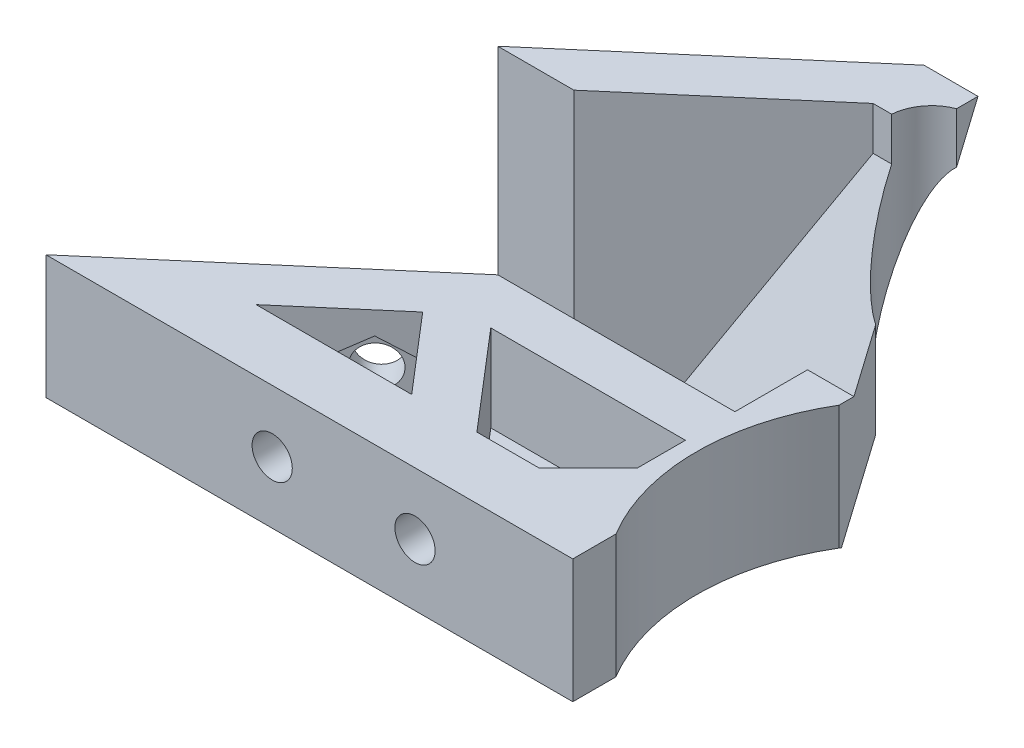
from build123d import *

# Parameters (mm, degrees)
CROQUIS1_R                              = 15.25
CROQUIS1_R_2                            = 2.125
SOPORTE_CAJA_REDUCTORA_DEPTH            = 20
CROQUIS3_R                              = 2.125
CORTAR_EXTRUIR1_DEPTH                   = 51.423828692
REDONDEO1_R                             = 5
BOSS_EXTRUDE1_DEPTH                     = 20
CUT_EXTRUDE1_REACH                      = 55.852
SKETCH2_R                               = 1.625
CUT_EXTRUDE2_DEPTH                      = 2
SKETCH4_R                               = 1.625
CUT_EXTRUDE3_DEPTH                      = 63.291652731
CUT_EXTRUDE4_START                      = -4.5
CUT_EXTRUDE4_DEPTH                      = 2
CROQUIS6_W                              = 4.75
CROQUIS6_H                              = 4.75
CORTAR_EXTRUIR17_DEPTH                  = 42.231056256
CROQUIS7_W                              = 60
CROQUIS7_H                              = 20
CORTAR_EXTRUIR18_DEPTH                  = 51.423828692
SALIENTE_EXTRUIR2_DEPTH                 = 49
SOPORTE_START                           = -15
SOPORTE_MOTOR_DEPTH                     = 15
CROQUIS12_R                             = 2.125
AGUJEROS_DE_SUJECION_A_BASE_DEPTH       = 84.087679592
TUERCA_START                            = -4
TUERCA_AGUJERO_DE_SUJECION_A_BASE_DEPTH = 10
SALIENTE_EXTRUIR4_DEPTH                 = 15
CORTAR_EXTRUIR19_DEPTH                  = 25
CROQUIS14_W                             = 50
CROQUIS14_H                             = 118
CORTAR_EXTRUIR22_DEPTH                  = 146.556045907
CROQUIS15_W                             = 10
CROQUIS15_H                             = 7
CORTAR_EXTRUIR23_DEPTH                  = 42.231056256
CORTAR_EXTRUIR24_DEPTH                  = 42.231056256
CROQUIS18_W                             = 40
CROQUIS18_H                             = 10
CORTAR_EXTRUIR25_DEPTH                  = 44.27311521
SALIENTE_EXTRUIR5_DEPTH                 = 10
CROQUIS20_R                             = 1
CORTAR_EXTRUIR26_DEPTH                  = 49.229270158
CORTAR_EXTRUIR27_REACH                  = 62.959
CORTAR_EXTRUIR27_END_RADIUS             = 15.25
CROQUIS21_R                             = 1.625
CROQUIS22_R                             = 2.125
CROQUIS22_R_2                           = 1
SALIENTE_EXTRUIR6_DEPTH                 = 10
CROQUIS23_R                             = 1.625
CORTAR_EXTRUIR28_DEPTH                  = 52.269508521
CORTAR_EXTRUIR29_START                  = -3
CORTAR_EXTRUIR29_DEPTH                  = 10
SALIENTE_EXTRUIR7_DEPTH                 = 10
CORTAR_EXTRUIR30_REACH                  = 72.235
CROQUIS27_R                             = 1.625
CORTAR_EXTRUIR31_REACH                  = 75.235
CORTAR_EXTRUIR31_START                  = -3
CORTAR_EXTRUIR32_REACH                  = 58.612
CROQUIS29_R                             = 1.625
CORTAR_EXTRUIR33_REACH                  = 61.112
CORTAR_EXTRUIR33_START                  = -2.5
CROQUIS35_W                             = 13.305418987
CROQUIS35_H                             = 6.826864192
CORTAR_EXTRUIR34_DEPTH                  = 63.931555098
CORTAR_EXTRUIR34_DEPTH_BACK             = 63.931555098
CORTAR_EXTRUIR35_START                  = -3
CORTAR_EXTRUIR35_DEPTH                  = 10
SALIENTE_EXTRUIR8_DEPTH                 = 10
SALIENTE_EXTRUIR9_DEPTH                 = 13
SALIENTE_EXTRUIR10_DEPTH                = 3
CROQUIS40_W                             = 106.583537839
CROQUIS40_H                             = 47.391515964
CORTAR_EXTRUIR36_DEPTH                  = 80.887064817
CORTAR_EXTRUIR36_DEPTH_BACK             = 80.887064817
CROQUIS41_W                             = 24.558856908
CROQUIS41_H                             = 18.206234432
CORTAR_EXTRUIR37_DEPTH                  = 80.887064817
CORTAR_EXTRUIR37_DEPTH_BACK             = 80.887064817
CROQUIS42_W                             = 39.793611955
CROQUIS42_H                             = 36.552695193
CORTAR_EXTRUIR38_DEPTH                  = 63.931555082
CORTAR_EXTRUIR38_DEPTH_BACK             = 63.931555082
SALIENTE_EXTRUIR11_DEPTH                = 3
CROQUIS44_R                             = 17.5
CORTAR_EXTRUIR39_DEPTH                  = 63.931555082
CORTAR_EXTRUIR39_DEPTH_BACK             = 63.931555082
SALIENTE_EXTRUIR12_DEPTH                = 16
CORTAR_EXTRUIR40_DEPTH                  = 66.79232953
SALIENTE_EXTRUIR14_DEPTH                = 3
CROQUIS48_R                             = 17.5
CORTAR_EXTRUIR41_DEPTH                  = 68.352658633
CORTAR_EXTRUIR41_DEPTH_BACK             = 68.352658633
CROQUIS49_R                             = 3.5
CORTAR_EXTRUIR42_DEPTH                  = 68.352658633


with BuildPart() as part:
    # Croquis1 → Soporte caja reductora (new body)
    with BuildSketch(Plane(origin=(0, 0, 0), x_dir=(1, 0, 0), z_dir=(0, 1, 0))):
        Polygon((-30, -15.25), (-20, -15.25), (-20, -20), (20, -20), (20, -15.25), (30, -15.25), (30, -7.25), (20, -4.25), (20, 20), (-20, 20), (-20, -4.25), (-30, -7.25), align=None)
        with Locations(Location((0, 0, 0), (0, 0, 270))):
            Circle(CROQUIS1_R, mode=Mode.SUBTRACT)
        with Locations(Location((-15, 15, 0), (0, 0, 270))):
            Circle(CROQUIS1_R_2, mode=Mode.SUBTRACT)
        with Locations(Location((15, 15, 0), (0, 0, 270))):
            Circle(CROQUIS1_R_2, mode=Mode.SUBTRACT)
    extrude(amount=-SOPORTE_CAJA_REDUCTORA_DEPTH)

    # Croquis3 → Cortar-Extruir1 (cut, through all)
    with BuildSketch(Plane.XY.offset(15.25)):
        with Locations((-23.5, -10)):
            Circle(CROQUIS3_R)
        with Locations((23.5, -10)):
            Circle(CROQUIS3_R)
    extrude(amount=-CORTAR_EXTRUIR1_DEPTH, mode=Mode.SUBTRACT)

    # Redondeo1
    redondeo1_edges = [part.edges().sort_by_distance(p)[0] for p in [
        (-20, -10, -20),
        (20, -10, -20),
    ]]
    fillet(redondeo1_edges, radius=REDONDEO1_R)

    # Sketch1 → Boss-Extrude1 (add)
    with BuildSketch(Plane(origin=(0, 0, 0), x_dir=(1, 0, 0), z_dir=(0, 1, 0))):
        with BuildLine():
            Line((25.5, 15), (20, 15))
            ThreePointArc((20, 15), (18.535533906, 18.535533906), (15, 20))
            Line((15, 20), (30, 20))
            Line((30, 20), (30, 8))
            Line((30, 8), (25.5, 8))
            Line((25.5, 8), (25.5, 15))
        make_face()
    extrude(amount=-BOSS_EXTRUDE1_DEPTH)

    # Sketch2 → Cut-Extrude1 (cut, up to next)
    with BuildSketch(Plane(origin=(0, 0, -20), x_dir=(-1, 0, 0), z_dir=(0, 0, -1)), mode=Mode.PRIVATE) as cut_extrude1_sk1:
        with Locations((-22.75, -10)):
            Circle(SKETCH2_R)
    cut_extrude1_tool1 = extrude(cut_extrude1_sk1.sketch, amount=-CUT_EXTRUDE1_REACH, mode=Mode.PRIVATE) & part.part
    add(cut_extrude1_tool1.solids().sort_by_distance((22.75, -10, -20))[0], mode=Mode.SUBTRACT)

    # Sketch3 → Cut-Extrude2 (cut)
    with BuildSketch(Plane.XY.offset(-15)):
        Polygon((20, -11.58771324), (22.75, -13.175426481), (25.5, -11.58771324), (25.5, -8.41228676), (22.75, -6.824573519), (20, -8.41228676), align=None)
    extrude(amount=-CUT_EXTRUDE2_DEPTH, mode=Mode.SUBTRACT)

    # Sketch4 → Cut-Extrude3 (cut, through all)
    with BuildSketch(Plane.ZY.offset(-25.5)):
        with Locations((-12.25, -10)):
            Circle(SKETCH4_R)
    extrude(amount=-CUT_EXTRUDE3_DEPTH, mode=Mode.SUBTRACT)

    # Sketch5 → Cut-Extrude4 (cut)
    with BuildSketch(Plane(origin=(30, 0, 0), x_dir=(0, 0, -1), z_dir=(1, 0, 0)).offset(CUT_EXTRUDE4_START)):
        Polygon((15, -11.58771324), (15, -8.41228676), (12.25, -6.824573519), (9.5, -8.41228676), (9.5, -11.58771324), (12.25, -13.175426481), align=None)
    extrude(amount=CUT_EXTRUDE4_DEPTH, mode=Mode.SUBTRACT)

    # Croquis6 → Cortar-Extruir17 (cut, through all)
    with BuildSketch(Plane(origin=(0, 0, 0), x_dir=(1, 0, 0), z_dir=(0, 1, 0))):
        Polygon((0, -15.25), (-15.25, -15.25), (-15.25, -20), (15.25, -20), (15.25, -15.25), align=None)
        with Locations((-17.625, -17.625)):
            Rectangle(CROQUIS6_W, CROQUIS6_H)
        with BuildLine():
            ThreePointArc((0, -15.25), (-10.783378413, -10.783378413), (-15.25, 0))
            Line((-15.25, 0), (-15.25, -15.25))
            Line((-15.25, -15.25), (0, -15.25))
        make_face()
        with BuildLine():
            Line((15.25, -15.25), (15.25, 0))
            ThreePointArc((15.25, 0), (10.783378413, -10.783378413), (0, -15.25))
            Line((0, -15.25), (15.25, -15.25))
        make_face()
        with Locations((17.625, -17.625)):
            Rectangle(CROQUIS6_W, CROQUIS6_H)
    extrude(amount=-CORTAR_EXTRUIR17_DEPTH, mode=Mode.SUBTRACT)


with BuildPart() as body_2:
    # Simetría1: mirrored copy
    add(part.part.mirror(Plane.ZX))

    # Croquis8 → Saliente-Extruir2 (add)
    with BuildSketch(Plane(origin=(0, 20, 0), x_dir=(1, 0, 0), z_dir=(0, 1, 0))):
        with BuildLine():
            Line((-12.664515522, 20), (-11.040489496, 13.939052358))
            Line((-11.040489496, 13.939052358), (-10.315162126, 11.232093763))
            ThreePointArc((-10.315162126, 11.232093763), (0, 15.25), (10.315162126, 11.232093763))
            Line((10.315162126, 11.232093763), (10.817418481, 13.87928066))
            Line((10.817418481, 13.87928066), (11.978715476, 20))
            Line((11.978715476, 20), (-12.664515522, 20))
        make_face()
    extrude(amount=SALIENTE_EXTRUIR2_DEPTH)

    # Croquis9 → Soporte motor (add)
    with BuildSketch(Plane(origin=(0, 69, 0), x_dir=(1, 0, 0), z_dir=(0, 1, 0)).offset(SOPORTE_START)):
        with BuildLine():
            Line((-20, 15), (-20, -4.25))
            Line((-20, -4.25), (-30, -7.25))
            Line((-30, -7.25), (-30, -15.25))
            Line((-30, -15.25), (0, -15.25))
            Line((0, -15.25), (0, -14.75))
            ThreePointArc((0, -14.75), (-10.429825023, 10.429825023), (14.75, 0))
            Line((14.75, 0), (20, 0))
            Line((20, 0), (20, 13.936837101))
            Line((20, 13.936837101), (12.664515522, 20))
            Line((12.664515522, 20), (-15, 20))
            ThreePointArc((-15, 20), (-18.535533906, 18.535533906), (-20, 15))
        make_face()
    extrude(amount=-SOPORTE_MOTOR_DEPTH)

    # Croquis12 → Agujeros de sujecion a base (cut, through all)
    with BuildSketch(Plane.XY.offset(15.25)):
        with Locations((-23.5, 46.5)):
            Circle(CROQUIS12_R)
    extrude(amount=-AGUJEROS_DE_SUJECION_A_BASE_DEPTH, mode=Mode.SUBTRACT)

    # Croquis13 → Tuerca Agujero de sujecion a base (cut)
    with BuildSketch(Plane.XY.offset(15.25).offset(TUERCA_START)):
        Polygon((-20, 44.479274058), (-20, 48.520725942), (-23.5, 50.541451884), (-27, 48.520725942), (-27, 44.479274058), (-23.5, 42.458548116), align=None)
    extrude(amount=-TUERCA_AGUJERO_DE_SUJECION_A_BASE_DEPTH, mode=Mode.SUBTRACT)

    # Croquis10 → Saliente-Extruir4 (add)
    with BuildSketch(Plane(origin=(0, 69, 0), x_dir=(1, 0, 0), z_dir=(0, 1, 0))):
        with BuildLine():
            ThreePointArc((10.315162126, 11.232093763), (0, 15.25), (-10.315162126, 11.232093763))
            Line((-10.315162126, 11.232093763), (-10.16850369, 10.684757026))
            ThreePointArc((-10.16850369, 10.684757026), (0, 14.75), (10.16850369, 10.684757026))
            Line((10.16850369, 10.684757026), (10.315162126, 11.232093763))
        make_face()
    extrude(amount=-SALIENTE_EXTRUIR4_DEPTH)

    # Croquis11 → Cortar-Extruir19 (cut)
    with BuildSketch(Plane.XZ):
        with BuildLine():
            Line((15.25, 4.25), (20, 4.25))
            Line((20, 4.25), (21.972856468, 4.84185694))
            ThreePointArc((21.972856468, 4.84185694), (19.948931102, 10.40625523), (16.543503257, 15.25))
            Line((16.543503257, 15.25), (15.25, 15.25))
            Line((15.25, 15.25), (15.25, 4.25))
        make_face()
        with BuildLine():
            Line((21.972856468, 4.84185694), (30, 7.25))
            Line((30, 7.25), (30, 15.25))
            Line((30, 15.25), (16.543503257, 15.25))
            ThreePointArc((16.543503257, 15.25), (19.948931102, 10.40625523), (21.972856468, 4.84185694))
        make_face()
        with BuildLine():
            ThreePointArc((20, -15), (18.535533906, -18.535533906), (15, -20))
            Line((15, -20), (30, -20))
            Line((30, -20), (30, -8))
            Line((30, -8), (25.5, -8))
            Line((25.5, -8), (25.5, -15))
            Line((25.5, -15), (20, -15))
        make_face()
    extrude(amount=-CORTAR_EXTRUIR19_DEPTH, mode=Mode.SUBTRACT)

    # Simetría2: body 2 across face


with BuildPart() as part_1:
    add(part.part)

    # Croquis7 → Cortar-Extruir18 (cut, through all)
    with BuildSketch(Plane(origin=(0, 0, -20), x_dir=(-1, 0, 0), z_dir=(0, 0, -1))):
        with Locations((0, -10)):
            Rectangle(CROQUIS7_W, CROQUIS7_H)
    extrude(amount=-CORTAR_EXTRUIR18_DEPTH, mode=Mode.SUBTRACT)


with BuildPart() as body_2_1:
    add(body_2.part)
    add(body_2.part.mirror(Plane(origin=(-0.229209569, 69, -16.663998028), x_dir=(0, 0, 1), z_dir=(0, 1, 0))))

    # Croquis14 → Cortar-Extruir22 (cut, through all)
    with BuildSketch(Plane.XY.offset(15.25)):
        with Locations((-5, 79)):
            Rectangle(CROQUIS14_W, CROQUIS14_H)
    extrude(amount=-CORTAR_EXTRUIR22_DEPTH, mode=Mode.SUBTRACT)

    # Croquis15 → Cortar-Extruir23 (cut, through all)
    with BuildSketch(Plane.XZ):
        with Locations((-25, 7.75)):
            Rectangle(CROQUIS15_W, CROQUIS15_H)
    extrude(amount=-CORTAR_EXTRUIR23_DEPTH, mode=Mode.SUBTRACT)

    # Croquis16 → Cortar-Extruir24 (cut, through all)
    with BuildSketch(Plane.XZ):
        Polygon((-30, 15.25), (-15.25, 15.25), (-15.25, 12.75), (-20, 12.75), (-20, 11.25), (-30, 11.25), (-30, 12.75), align=None)
    extrude(amount=-CORTAR_EXTRUIR24_DEPTH, mode=Mode.SUBTRACT)

    # Croquis18 → Cortar-Extruir25 (cut, through all)
    with BuildSketch(Plane(origin=(0, 0, -20), x_dir=(-1, 0, 0), z_dir=(0, 0, -1))):
        with Locations((0, 5)):
            Rectangle(CROQUIS18_W, CROQUIS18_H)
    extrude(amount=-CORTAR_EXTRUIR25_DEPTH, mode=Mode.SUBTRACT)

    # Croquis19 → Saliente-Extruir5 (add)
    with BuildSketch(Plane(origin=(0, 20, 0), x_dir=(1, 0, 0), z_dir=(0, 1, 0))):
        Polygon((-20, -12.75), (-34, -12.75), (-34, -7.75), (-24, -7.75), (-20, -3.75), align=None)
    extrude(amount=-SALIENTE_EXTRUIR5_DEPTH)

    # Croquis20 → Cortar-Extruir26 (cut, through all)
    with BuildSketch(Plane(origin=(0, 0, 7.75), x_dir=(-1, 0, 0), z_dir=(0, 0, -1))):
        with Locations((29, 15)):
            Circle(CROQUIS20_R)
    extrude(amount=-CORTAR_EXTRUIR26_DEPTH, mode=Mode.SUBTRACT)

    # Cortar-Extruir27: up to this cylinder (the profile starts outside it)
    cortar_extruir27_end = Plane(origin=(0, 15, 0), z_dir=(0, -1, 0)) * Cylinder(CORTAR_EXTRUIR27_END_RADIUS, 157.418, mode=Mode.PRIVATE)
    # Croquis21 → Cortar-Extruir27 (cut, up to the surface)
    with BuildSketch(Plane(origin=(20, 0, 0), x_dir=(0, 0, -1), z_dir=(1, 0, 0)), mode=Mode.PRIVATE) as cortar_extruir27_sk1:
        with Locations((4.75, 15)):
            Circle(CROQUIS21_R)
    cortar_extruir27_tool1 = extrude(cortar_extruir27_sk1.sketch, amount=-CORTAR_EXTRUIR27_REACH, mode=Mode.PRIVATE) - cortar_extruir27_end
    add(cortar_extruir27_tool1.solids().sort_by_distance((20, 15, -4.75))[0], mode=Mode.SUBTRACT)

    # Croquis22 → Saliente-Extruir6 (add)
    with BuildSketch(Plane.XZ.offset(-10)):
        with Locations((-15, -15)):
            Circle(CROQUIS22_R)
        with Locations(Location((-15, -15, 0), (0, 0, 270))):
            Circle(CROQUIS22_R_2, mode=Mode.SUBTRACT)
        with Locations((15, -15)):
            Circle(CROQUIS22_R)
        with Locations(Location((15, -15, 0), (0, 0, 270))):
            Circle(CROQUIS22_R_2, mode=Mode.SUBTRACT)
    extrude(amount=-SALIENTE_EXTRUIR6_DEPTH)

    # Croquis23 → Cortar-Extruir28 (cut, through all)
    with BuildSketch(Plane(origin=(0, 0, -20), x_dir=(-1, 0, 0), z_dir=(0, 0, -1))):
        with Locations((0, 15)):
            Circle(CROQUIS23_R)
    extrude(amount=-CORTAR_EXTRUIR28_DEPTH, mode=Mode.SUBTRACT)

    # Croquis24 → Cortar-Extruir29 (cut)
    with BuildSketch(Plane(origin=(0, 0, -20), x_dir=(-1, 0, 0), z_dir=(0, 0, -1)).offset(CORTAR_EXTRUIR29_START)):
        Polygon((1.58771324, 12.25), (3.175426481, 15), (1.58771324, 17.75), (-1.58771324, 17.75), (-3.175426481, 15), (-1.58771324, 12.25), align=None)
    extrude(amount=-CORTAR_EXTRUIR29_DEPTH, mode=Mode.SUBTRACT)

    # Croquis26 → Saliente-Extruir7 (add)
    with BuildSketch(Plane.XZ.offset(-10)):
        Polygon((-34, 7.75), (-34, 12.75), (-58.825, 12.75), (-39.160527763, -4.104491148), (-20, -4.104491148), (-20, -0.104491148), (-35.732113118, -0.104491148), (-29, 7.75), align=None)
        Polygon((-34.268209086, 7.75), (-39.594516123, 1.535690951), (-46.844874897, 7.75), align=None, mode=Mode.SUBTRACT)
    extrude(amount=-SALIENTE_EXTRUIR7_DEPTH)

    # Croquis27 → Cortar-Extruir30 (cut, up to next)
    with BuildSketch(Plane.XY.offset(12.75), mode=Mode.PRIVATE) as cortar_extruir30_sk1:
        with Locations((-40.544874897, 15)):
            Circle(CROQUIS27_R)
    cortar_extruir30_tool1 = extrude(cortar_extruir30_sk1.sketch, amount=-CORTAR_EXTRUIR30_REACH, mode=Mode.PRIVATE) & body_2_1.part
    # Croquis27 → Cortar-Extruir30 (cut, up to next)
    with BuildSketch(Plane.XY.offset(12.75), mode=Mode.PRIVATE) as cortar_extruir30_sk2:
        with Locations((-29, 15)):
            Circle(CROQUIS27_R)
    cortar_extruir30_tool2 = extrude(cortar_extruir30_sk2.sketch, amount=-CORTAR_EXTRUIR30_REACH, mode=Mode.PRIVATE) & body_2_1.part
    add(cortar_extruir30_tool1.solids().sort_by_distance((-40.544875, 15, 12.75))[0], mode=Mode.SUBTRACT)
    add(cortar_extruir30_tool2.solids().sort_by_distance((-29, 15, 12.75))[0], mode=Mode.SUBTRACT)

    # Croquis28 → Cortar-Extruir31 (cut, up to next)
    with BuildSketch(Plane.XY.offset(12.75).offset(CORTAR_EXTRUIR31_START), mode=Mode.PRIVATE) as cortar_extruir31_sk1:
        Polygon((-38.957161657, 12.25), (-37.369448416, 15), (-38.957161657, 17.75), (-42.132588137, 17.75), (-43.720301378, 15), (-42.132588137, 12.25), align=None)
    cortar_extruir31_tool1 = extrude(cortar_extruir31_sk1.sketch, amount=-CORTAR_EXTRUIR31_REACH, mode=Mode.PRIVATE) & body_2_1.part
    # Croquis28 → Cortar-Extruir31 (cut, up to next)
    with BuildSketch(Plane.XY.offset(12.75).offset(CORTAR_EXTRUIR31_START), mode=Mode.PRIVATE) as cortar_extruir31_sk2:
        Polygon((-27.41228676, 12.25), (-25.824573519, 15), (-27.41228676, 17.75), (-30.58771324, 17.75), (-32.175426481, 15), (-30.58771324, 12.25), align=None)
    cortar_extruir31_tool2 = extrude(cortar_extruir31_sk2.sketch, amount=-CORTAR_EXTRUIR31_REACH, mode=Mode.PRIVATE) & body_2_1.part
    add(cortar_extruir31_tool1.solids().sort_by_distance((-40.544875, 15, 9.75))[0], mode=Mode.SUBTRACT)
    add(cortar_extruir31_tool2.solids().sort_by_distance((-29, 15, 9.75))[0], mode=Mode.SUBTRACT)

    # Croquis29 → Cortar-Extruir32 (cut, up to next)
    with BuildSketch(Plane(origin=(-18.612848159, 0, -21.715982563), x_dir=(-0.7592713073348843, 0, 0.6507742172658468), z_dir=(-0.6507742172658468, 0, -0.7592713073348843)), mode=Mode.PRIVATE) as cortar_extruir32_sk1:
        with Locations((33.812368097, 15)):
            Circle(CROQUIS29_R)
    cortar_extruir32_tool1 = extrude(cortar_extruir32_sk1.sketch, amount=-CORTAR_EXTRUIR32_REACH, mode=Mode.PRIVATE) & body_2_1.part
    add(cortar_extruir32_tool1.solids().sort_by_distance((-44.285609, 15, 0.288235))[0], mode=Mode.SUBTRACT)

    # Croquis31 → Cortar-Extruir33 (cut, up to next)
    with BuildSketch(Plane(origin=(-18.612848159, 0, -21.715982563), x_dir=(-0.7592713073348843, 0, 0.6507742172658468), z_dir=(-0.6507742172658468, 0, -0.7592713073348843)).offset(CORTAR_EXTRUIR33_START), mode=Mode.PRIVATE) as cortar_extruir33_sk1:
        Polygon((36.562368097, 16.58771324), (33.812368097, 18.175426481), (31.062368097, 16.58771324), (31.062368097, 13.41228676), (33.812368097, 11.824573519), (36.562368097, 13.41228676), align=None)
    cortar_extruir33_tool1 = extrude(cortar_extruir33_sk1.sketch, amount=-CORTAR_EXTRUIR33_REACH, mode=Mode.PRIVATE) & body_2_1.part
    add(cortar_extruir33_tool1.solids().sort_by_distance((-42.658674, 15, 2.186413))[0], mode=Mode.SUBTRACT)

    # Croquis35 → Cortar-Extruir34 (cut, two sides)
    with BuildSketch(Plane(origin=(0, 20, 0), x_dir=(1, 0, 0), z_dir=(0, 1, 0))) as cortar_extruir34_sk:
        with Locations((17.04227466, -3.413432096)):
            Rectangle(CROQUIS35_W, CROQUIS35_H)
    extrude(amount=CORTAR_EXTRUIR34_DEPTH, mode=Mode.SUBTRACT)
    extrude(cortar_extruir34_sk.sketch, amount=-CORTAR_EXTRUIR34_DEPTH_BACK, mode=Mode.SUBTRACT)

    # Croquis36 → Cortar-Extruir35 (cut)
    with BuildSketch(Plane(origin=(20, 0, 0), x_dir=(0, 0, -1), z_dir=(1, 0, 0)).offset(CORTAR_EXTRUIR35_START)):
        Polygon((7.5, 16.58771324), (4.75, 18.175426481), (2, 16.58771324), (2, 13.41228676), (4.75, 11.824573519), (7.5, 13.41228676), align=None)
    extrude(amount=-CORTAR_EXTRUIR35_DEPTH, mode=Mode.SUBTRACT)

    # Croquis37 → Saliente-Extruir8 (add)
    with BuildSketch(Plane.XZ.offset(-10)):
        Polygon((-39.160527763, -4.104491148), (-20.614919368, -20), (-15, -20), (-19.558128305, -15.637570403), (-33.014002756, -4.104491148), align=None)
    extrude(amount=-SALIENTE_EXTRUIR8_DEPTH)

    # Croquis38 → Saliente-Extruir9 (add)
    with BuildSketch(Plane.XZ.offset(-10)):
        Polygon((-58.825, 12.75), (-38.825, 12.75), (-38.825, 9.75), (-55.324839942, 9.75), align=None)
    extrude(amount=SALIENTE_EXTRUIR9_DEPTH)

    # Croquis39 → Saliente-Extruir10 (add)
    with BuildSketch(Plane.XZ.offset(-10)):
        Polygon((-38.825, 9.75), (-38.825, 7.75), (-38.825, 5.75), (-50.657959865, 5.75), (-52.991399903, 7.75), (-55.324839942, 9.75), align=None)
    extrude(amount=SALIENTE_EXTRUIR10_DEPTH)

    # Simetría3: body 2 across face


with BuildPart() as body_2_2:
    add(body_2_1.part)
    add(body_2_1.part.mirror(Plane(origin=(-18.003999227, 20, -4.220503046), x_dir=(0, 0, 1), z_dir=(0, 1, 0))))

    # Croquis40 → Cortar-Extruir36 (cut, two sides)
    with BuildSketch(Plane(origin=(0, 0, -20), x_dir=(-1, 0, 0), z_dir=(0, 0, -1))) as cortar_extruir36_sk:
        with Locations((22.395502026, -3.695757982)):
            Rectangle(CROQUIS40_W, CROQUIS40_H)
    extrude(amount=CORTAR_EXTRUIR36_DEPTH, mode=Mode.SUBTRACT)
    extrude(cortar_extruir36_sk.sketch, amount=-CORTAR_EXTRUIR36_DEPTH_BACK, mode=Mode.SUBTRACT)

    # Croquis41 → Cortar-Extruir37 (cut, two sides)
    with BuildSketch(Plane(origin=(0, 0, -20), x_dir=(-1, 0, 0), z_dir=(0, 0, -1))) as cortar_extruir37_sk:
        with Locations((51.104428454, 39.103117216)):
            Rectangle(CROQUIS41_W, CROQUIS41_H)
    extrude(amount=CORTAR_EXTRUIR37_DEPTH, mode=Mode.SUBTRACT)
    extrude(cortar_extruir37_sk.sketch, amount=-CORTAR_EXTRUIR37_DEPTH_BACK, mode=Mode.SUBTRACT)

    # Croquis42 → Cortar-Extruir38 (cut, two sides)
    with BuildSketch(Plane.XZ.offset(-20)) as cortar_extruir38_sk:
        with Locations((3.646805978, -5.526347597)):
            Rectangle(CROQUIS42_W, CROQUIS42_H)
    extrude(amount=CORTAR_EXTRUIR38_DEPTH, mode=Mode.SUBTRACT)
    extrude(cortar_extruir38_sk.sketch, amount=-CORTAR_EXTRUIR38_DEPTH_BACK, mode=Mode.SUBTRACT)

    # Croquis43 → Saliente-Extruir11 (add)
    with BuildSketch(Plane.XZ.offset(-20)):
        Polygon((-46.844874897, 7.75), (-19.56186566, 7.75), (-19.56186566, -16.371419699), align=None)
    extrude(amount=-SALIENTE_EXTRUIR11_DEPTH)

    # Croquis44 → Cortar-Extruir39 (cut, two sides)
    with BuildSketch(Plane(origin=(0, 30, 0), x_dir=(1, 0, 0), z_dir=(0, 1, 0))) as cortar_extruir39_sk:
        with Locations((-1.25, -0.25)):
            Circle(CROQUIS44_R)
    extrude(amount=CORTAR_EXTRUIR39_DEPTH, mode=Mode.SUBTRACT)
    extrude(cortar_extruir39_sk.sketch, amount=-CORTAR_EXTRUIR39_DEPTH_BACK, mode=Mode.SUBTRACT)

    # Croquis45 → Saliente-Extruir12 (add)
    with BuildSketch(Plane(origin=(0, 30, 0), x_dir=(1, 0, 0), z_dir=(0, 1, 0))):
        Polygon((-33.014002756, 4.104491148), (-39.160527763, 4.104491148), (-20.614919368, 20), (-16.25, 20), (-16.25, 15.264857309), (-19.992980133, 15.264857309), align=None)
    extrude(amount=SALIENTE_EXTRUIR12_DEPTH)

    # Croquis46 → Cortar-Extruir40 (cut, through all)
    with BuildSketch(Plane(origin=(-16.25, 0, 0), x_dir=(0, 0, -1), z_dir=(1, 0, 0))):
        Polygon((9, 20), (20, 46), (20, 20), align=None)
    extrude(amount=-CORTAR_EXTRUIR40_DEPTH, mode=Mode.SUBTRACT)

    # Croquis47 → Saliente-Extruir14 (add)
    with BuildSketch(Plane(origin=(0, -0.193224592, -0.456712673), x_dir=(-1, 0, 0), z_dir=(0, -0.38963999083669787, -0.9209672510685588))):
        Polygon((16.25, 21.834102438), (33.44883958, 21.926104939), (22.720097697, 45.526464663), (16.25, 45.526464663), align=None)
    extrude(amount=-SALIENTE_EXTRUIR14_DEPTH)

    # Croquis48 → Cortar-Extruir41 (cut, two sides)
    with BuildSketch(Plane.XZ.offset(-20)) as cortar_extruir41_sk:
        with Locations((-1.25, 0.25)):
            Circle(CROQUIS48_R)
    extrude(amount=CORTAR_EXTRUIR41_DEPTH, mode=Mode.SUBTRACT)
    extrude(cortar_extruir41_sk.sketch, amount=-CORTAR_EXTRUIR41_DEPTH_BACK, mode=Mode.SUBTRACT)

    # Croquis49 → Cortar-Extruir42 (cut, through all)
    with BuildSketch(Plane.XZ.offset(-20)):
        with Locations((-15, -15)):
            Circle(CROQUIS49_R)
    extrude(amount=-CORTAR_EXTRUIR42_DEPTH, mode=Mode.SUBTRACT)


solid = body_2_2.part
